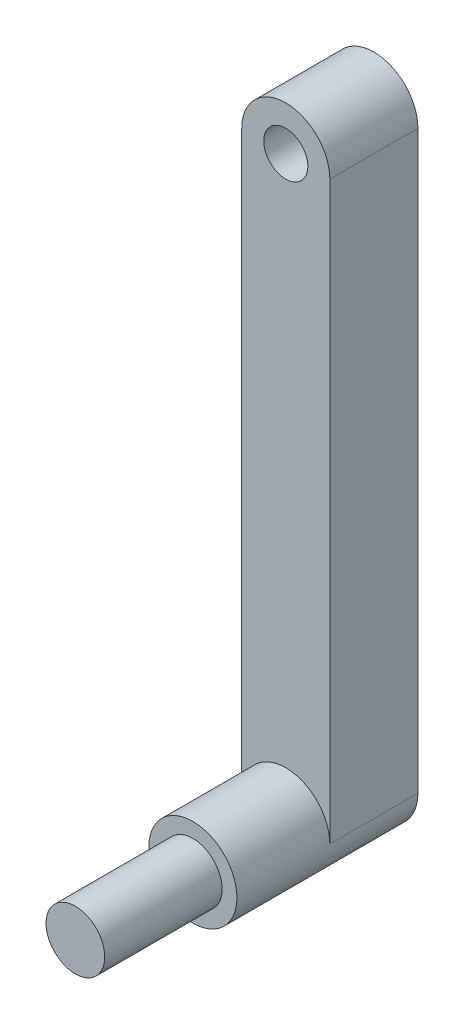
from build123d import *

# Parameters (mm, degrees)
SKETCH1_LINK3_R     = 20
BOSS_EXTRUDE1_DEPTH = 40
SKETCH2_LINK3_R     = 30
BOSS_EXTRUDE2_DEPTH = 63.3
SKETCH3_LINK3_R     = 15
BOSS_EXTRUDE3_DEPTH = 60
BOSS_EXTRUDE4_DEPTH = 0.1


with BuildPart() as part:
    # sketch1_link3 → Boss-Extrude1 (new body, symmetric)
    with BuildSketch(Plane.XY):
        Circle(SKETCH1_LINK3_R)
    extrude(amount=BOSS_EXTRUDE1_DEPTH, both=True)

    # sketch2_link3 → Boss-Extrude2 (add)
    with BuildSketch(Plane(origin=(0, 0, -40), x_dir=(-1, 0, 0), z_dir=(0, 0, -1))):
        Circle(SKETCH2_LINK3_R)
    extrude(amount=BOSS_EXTRUDE2_DEPTH)

    # sketch3_link3 → Boss-Extrude3 (add)
    with BuildSketch(Plane(origin=(0, 0, -103.3), x_dir=(-1, 0, 0), z_dir=(0, 0, -1))):
        with BuildLine():
            Line((-30, 0), (-30, 392.2))
            ThreePointArc((-30, 392.2), (0, 422.2), (30, 392.2))
            Line((30, 392.2), (30, 0))
            ThreePointArc((30, 0), (0, -30), (-30, 0))
        make_face()
        with Locations((0, 392.2)):
            Circle(SKETCH3_LINK3_R, mode=Mode.SUBTRACT)
    extrude(amount=BOSS_EXTRUDE3_DEPTH)

    # Sketch1 → Boss-Extrude4 (add)
    with BuildSketch(Plane(origin=(0, 0, -163.3), x_dir=(-1, 0, 0), z_dir=(0, 0, -1))):
        with BuildLine():
            Line((7.522174783, 134.249399585), (10, 134.249399585))
            Line((10, 134.249399585), (10, 136.696634368))
            add(Edge.make_bspline(
                [(10, 136.696634368), (9.997204903, 136.890906308), (9.991762515, 137.269176934), (9.932403331, 137.817256446), (9.84153359, 138.328261028), (9.712368999, 138.800593905), (9.551205587, 139.237248905), (9.345468962, 139.632434341), (9.106898281, 139.993681123), (8.914254013, 140.202260238), (8.818356938, 140.306089577)],
                knots=[0, 0, 0, 0, 0.000582594, 0.001134379, 0.001651743, 0.002138099, 0.002601693, 0.003045074, 0.003472233, 0.003895639, 0.003895639, 0.003895639, 0.003895639], degree=3))
            add(Edge.make_bspline(
                [(8.818356938, 140.306089577), (8.715773036, 140.401593755), (8.509158087, 140.593949383), (8.155363359, 140.838765952), (7.762731673, 141.040830434), (7.335121745, 141.211367397), (6.866877955, 141.3375283), (6.362036342, 141.428809453), (5.820670918, 141.488439288), (5.447666363, 141.493816755), (5.255725234, 141.496583898)],
                knots=[0, 0, 0, 0, 0.000420085, 0.000846097, 0.001285551, 0.001742485, 0.002224574, 0.002737584, 0.003280568, 0.003856172, 0.003856172, 0.003856172, 0.003856172], degree=3))
            Line((5.255725234, 141.496583898), (-11.1074, 141.499332628))
            Line((-11.1074, 141.499332628), (-11.1074, 138.715603063))
            Line((-11.1074, 138.715603063), (4.891397391, 138.715603063))
            add(Edge.make_bspline(
                [(4.891397391, 138.715603063), (5.113875157, 138.709389248), (5.527606615, 138.697833707), (6.094702581, 138.587548603), (6.570477779, 138.417232304), (6.811469375, 138.223649384), (6.924187535, 138.133105519)],
                knots=[0, 0, 0, 0, 0.000666363, 0.001239205, 0.001729831, 0.002160961, 0.002160961, 0.002160961, 0.002160961], degree=3))
            add(Edge.make_bspline(
                [(6.924187535, 138.133105519), (7.017801981, 138.022120901), (7.215235676, 137.788053356), (7.39227175, 137.322288951), (7.50844424, 136.768647227), (7.517031962, 136.363661229), (7.52164751, 136.145997898)],
                knots=[0, 0, 0, 0, 0.00043283, 0.000912843, 0.001473554, 0.002125085, 0.002125085, 0.002125085, 0.002125085], degree=3))
            Line((7.52164751, 136.145997898), (7.522174783, 134.249399585))
        make_face()
        with BuildLine():
            add(Edge.make_bspline(
                [(8.149278696, 148.26248533), (8.312284056, 148.450821439), (8.64098021, 148.830596403), (9.04839832, 149.474671574), (9.400009646, 150.168035775), (9.688619965, 150.915027756), (9.908283617, 151.716195033), (10.066182559, 152.570380208), (10.166025136, 153.478819295), (10.176221112, 154.103458883), (10.181450807, 154.423847509)],
                knots=[0, 0, 0, 0, 0.000746348, 0.001504992, 0.00227887, 0.003076085, 0.003902861, 0.004767389, 0.005679853, 0.006640714, 0.006640714, 0.006640714, 0.006640714], degree=3))
            add(Edge.make_bspline(
                [(10.181450807, 154.423847509), (10.176221122, 154.744236144), (10.166025165, 155.368875748), (10.066182453, 156.277314717), (9.908283984, 157.131500307), (9.688618678, 157.932666131), (9.400014212, 158.67966325), (9.04838195, 159.373009077), (8.64014015, 160.018573114), (8.309958135, 160.399301059), (8.145661262, 160.588749327)],
                knots=[0, 0, 0, 0, 0.000960861, 0.001873325, 0.002737853, 0.003564629, 0.004361844, 0.005135722, 0.005894366, 0.006645746, 0.006645746, 0.006645746, 0.006645746], degree=3))
            add(Edge.make_bspline(
                [(8.145661262, 160.588749327), (7.971032326, 160.765598355), (7.623328557, 161.11772255), (7.03352567, 161.569469278), (6.394021155, 161.954575023), (5.701623062, 162.268135578), (4.958062777, 162.5119028), (4.164694196, 162.68366789), (3.319979145, 162.785876486), (2.739307303, 162.799164055), (2.441024907, 162.805989679)],
                knots=[0, 0, 0, 0, 0.000744901, 0.001483172, 0.002221669, 0.002980209, 0.00375834, 0.004564789, 0.005411797, 0.006306475, 0.006306475, 0.006306475, 0.006306475], degree=3))
            Line((2.441024907, 162.805989679), (-11.1074, 162.808237069))
            Line((-11.1074, 162.808237069), (-11.1074, 160.024507504))
            Line((-11.1074, 160.024507504), (2.26062, 160.024507504))
            add(Edge.make_bspline(
                [(2.26062, 160.024507504), (2.481747634, 160.019728452), (2.910629485, 160.010459378), (3.531371444, 159.942085819), (4.111552413, 159.839459262), (4.648408374, 159.68466032), (5.142653648, 159.483694502), (5.597741883, 159.24618789), (6.008170627, 158.960827266), (6.374554833, 158.631131038), (6.694903235, 158.254685505), (6.975937952, 157.836858399), (7.209779798, 157.371802842), (7.404565775, 156.866534346), (7.555536313, 156.316565623), (7.659299503, 155.723850071), (7.72127444, 155.087534892), (7.729720802, 154.649698454), (7.734077724, 154.423847509)],
                knots=[0, 0, 0, 0, 0.000663246, 0.001286381, 0.001871435, 0.002428888, 0.002958967, 0.003469739, 0.003965726, 0.004454553, 0.00494418, 0.005444981, 0.005961567, 0.006502364, 0.007067131, 0.007669602, 0.008305492, 0.008982975, 0.008982975, 0.008982975, 0.008982975], degree=3))
            add(Edge.make_bspline(
                [(7.734077724, 154.423847509), (7.729720802, 154.197996564), (7.72127444, 153.760160126), (7.659299503, 153.123844947), (7.555536313, 152.531129395), (7.404565775, 151.981160672), (7.209779798, 151.475892175), (6.975937952, 151.010836621), (6.694903235, 150.593009502), (6.374554832, 150.216564018), (6.008170632, 149.886867611), (5.597741864, 149.601507669), (5.142653721, 149.363998399), (4.648408082, 149.163043105), (4.111553589, 149.008201919), (3.531366695, 148.905745891), (2.910328301, 148.836638743), (2.481058123, 148.829242426), (2.259574099, 148.82542626)],
                knots=[0, 0, 0, 0, 0.000677483, 0.001313374, 0.001915845, 0.002480611, 0.003021408, 0.003537995, 0.004038795, 0.004528423, 0.005017249, 0.005513236, 0.006024008, 0.006554087, 0.00711154, 0.007696595, 0.008319729, 0.008983942, 0.008983942, 0.008983942, 0.008983942], degree=3))
            Line((2.259574099, 148.82542626), (-11.1074, 148.828408374))
            Line((-11.1074, 148.828408374), (-11.1074, 146.044678808))
            Line((-11.1074, 146.044678808), (2.444162609, 146.044678808))
            add(Edge.make_bspline(
                [(2.444162609, 146.044678808), (2.741407481, 146.050278902), (3.321085003, 146.061200028), (4.164686986, 146.164213202), (4.958064596, 146.335745261), (5.701622595, 146.579571495), (6.394021276, 146.893116895), (7.033525638, 147.278226557), (7.623328565, 147.729972261), (7.971032328, 148.082096593), (8.145661262, 148.258945691)],
                knots=[0, 0, 0, 0, 0.00089143, 0.001738438, 0.002544887, 0.003323017, 0.004081558, 0.004820055, 0.005558326, 0.006303227, 0.006303227, 0.006303227, 0.006303227], degree=3))
            Line((8.145661262, 148.258945691), (8.149278696, 148.26248533))
        make_face()
        with BuildLine():
            add(Edge.make_bspline(
                [(8.59284, 168.327774931), (8.720690648, 168.507150573), (8.980068155, 168.871059618), (9.30145402, 169.47593218), (9.577037878, 170.131748473), (9.794642945, 170.844737361), (9.973704188, 171.606974968), (10.095436344, 172.423998107), (10.164890748, 173.293512587), (10.175827791, 173.890587982), (10.181450807, 174.197559873)],
                knots=[0, 0, 0, 0, 0.000660231, 0.001339446, 0.002049591, 0.002791461, 0.003572983, 0.004396673, 0.005266982, 0.006187896, 0.006187896, 0.006187896, 0.006187896], degree=3))
            add(Edge.make_bspline(
                [(10.181450807, 174.197559873), (10.176340347, 174.51489159), (10.166389656, 175.132775263), (10.089692931, 176.032784428), (9.968740969, 176.880630182), (9.792577856, 177.675634304), (9.562255827, 178.417062558), (9.28402116, 179.104629801), (8.957719835, 179.742021392), (8.692733943, 180.127530449), (8.56167043, 180.318205396)],
                knots=[0, 0, 0, 0, 0.000951881, 0.001853428, 0.002707758, 0.003519484, 0.004293565, 0.005034035, 0.005742689, 0.006436214, 0.006436214, 0.006436214, 0.006436214], degree=3))
            add(Edge.make_bspline(
                [(8.56167043, 180.318205396), (8.424219937, 180.493017195), (8.153115005, 180.837812909), (7.677867024, 181.286296082), (7.163329826, 181.669803902), (6.605415917, 181.98221942), (6.005452714, 182.222250284), (5.365494984, 182.394700381), (4.682241497, 182.497660943), (4.21311202, 182.510931186), (3.972292695, 182.517743231)],
                knots=[0, 0, 0, 0, 0.000666377, 0.00131435, 0.001953421, 0.002587461, 0.003226838, 0.003887088, 0.004571817, 0.005294063, 0.005294063, 0.005294063, 0.005294063], degree=3))
            add(Edge.make_bspline(
                [(3.972292695, 182.517743231), (3.77002483, 182.512003559), (3.374560915, 182.500781643), (2.795798967, 182.431807758), (2.251585712, 182.305643003), (1.736968641, 182.141175909), (1.261438918, 181.913521752), (0.809702279, 181.651629234), (0.39889761, 181.327336756), (0.012882298, 180.964284362), (-0.331664911, 180.543507554), (-0.645131399, 180.077232509), (-0.931809002, 179.56523901), (-1.176785726, 179.000317594), (-1.393494002, 178.387957053), (-1.578555436, 177.728696472), (-1.729740848, 177.020458635), (-1.801535922, 176.530344686), (-1.838558768, 176.277605712)],
                knots=[0, 0, 0, 0, 0.000606892, 0.001186565, 0.001744844, 0.002280857, 0.00280355, 0.003323463, 0.003843978, 0.004369865, 0.004910444, 0.0054714, 0.006053854, 0.006668124, 0.007316218, 0.008001334, 0.008720917, 0.009487075, 0.009487075, 0.009487075, 0.009487075], degree=3))
            Line((-1.838558768, 176.277605712), (-2.174993043, 173.3140158))
            add(Edge.make_bspline(
                [(-2.174993043, 173.3140158), (-2.199795166, 173.143544762), (-2.248011699, 172.812140764), (-2.346240966, 172.336489192), (-2.456062344, 171.894220637), (-2.583548533, 171.487408022), (-2.728446665, 171.11388167), (-2.893670555, 170.777985488), (-3.06733084, 170.471005887), (-3.208223686, 170.292592527), (-3.276888337, 170.205642113)],
                knots=[0, 0, 0, 0, 0.000516694, 0.001004477, 0.001456369, 0.001883276, 0.002282687, 0.002656777, 0.003005925, 0.003337848, 0.003337848, 0.003337848, 0.003337848], degree=3))
            add(Edge.make_bspline(
                [(-3.276888337, 170.205642113), (-3.347530094, 170.127325568), (-3.488306711, 169.971254446), (-3.72675607, 169.767624507), (-3.987754312, 169.59981453), (-4.262403523, 169.453705811), (-4.563515979, 169.350675192), (-4.881077898, 169.268483568), (-5.221589724, 169.226289788), (-5.454205799, 169.218371687), (-5.57379002, 169.214301117)],
                knots=[0, 0, 0, 0, 0.000316208, 0.000630147, 0.000937019, 0.0012458, 0.001560767, 0.001889219, 0.002228466, 0.002587379, 0.002587379, 0.002587379, 0.002587379], degree=3))
            add(Edge.make_bspline(
                [(-5.57379002, 169.214301117), (-5.709678782, 169.219198234), (-5.975306272, 169.228770837), (-6.362270717, 169.284520253), (-6.723543296, 169.386854296), (-7.057781578, 169.531289728), (-7.372225063, 169.706880695), (-7.656004706, 169.931709979), (-7.91622561, 170.195039534), (-8.064824894, 170.395459408), (-8.140655098, 170.497733656)],
                knots=[0, 0, 0, 0, 0.000407759, 0.000797063, 0.001169711, 0.001530583, 0.001887388, 0.002246819, 0.002612972, 0.002994527, 0.002994527, 0.002994527, 0.002994527], degree=3))
            add(Edge.make_bspline(
                [(-8.140655098, 170.497733656), (-8.21227436, 170.609999957), (-8.358816135, 170.83971055), (-8.540487469, 171.219471416), (-8.688110434, 171.639219428), (-8.818298974, 172.095072812), (-8.914173283, 172.591218317), (-8.976993062, 173.125351756), (-9.024779754, 173.695139303), (-9.028363381, 174.088284283), (-9.030206617, 174.290498091)],
                knots=[0, 0, 0, 0, 0.00039924, 0.000816894, 0.001259279, 0.001732843, 0.002237985, 0.002773194, 0.003345813, 0.003952269, 0.003952269, 0.003952269, 0.003952269], degree=3))
            add(Edge.make_bspline(
                [(-9.030206617, 174.290498091), (-9.028245469, 174.491220314), (-9.024447734, 174.879916109), (-8.978675009, 175.442788457), (-8.908485501, 175.967381418), (-8.813746888, 176.454879074), (-8.685319049, 176.903270827), (-8.529150969, 177.312816198), (-8.352016732, 177.688959761), (-8.201037035, 177.912328349), (-8.12737821, 178.021303714)],
                knots=[0, 0, 0, 0, 0.000602032, 0.001165827, 0.00169283, 0.00218929, 0.002654339, 0.003089966, 0.003503638, 0.003897718, 0.003897718, 0.003897718, 0.003897718], degree=3))
            add(Edge.make_bspline(
                [(-8.12737821, 178.021303714), (-8.050278011, 178.122371942), (-7.897141767, 178.323113433), (-7.62181519, 178.584800719), (-7.32107509, 178.815475721), (-6.99220558, 179.012127902), (-6.631310042, 179.167875726), (-6.242262606, 179.289037333), (-5.825539193, 179.386078264), (-5.535944561, 179.414252276), (-5.387913583, 179.428653878)],
                knots=[0, 0, 0, 0, 0.000380836, 0.000756415, 0.001135265, 0.001516281, 0.001902732, 0.002311427, 0.002737691, 0.003183429, 0.003183429, 0.003183429, 0.003183429], degree=3))
            Line((-5.387913583, 179.428653878), (-5.386988696, 182.124061018))
            add(Edge.make_bspline(
                [(-5.386988696, 182.124061018), (-5.628590508, 182.094948059), (-6.099154812, 182.038245176), (-6.775046283, 181.873658729), (-7.407304526, 181.667667891), (-7.995724135, 181.407874037), (-8.533210838, 181.085292136), (-9.028475589, 180.716376837), (-9.480824673, 180.294903719), (-9.740432555, 179.974780636), (-9.871076212, 179.813683639)],
                knots=[0, 0, 0, 0, 0.000729467, 0.001420773, 0.002082741, 0.002722623, 0.003345758, 0.00395915, 0.004572799, 0.005194438, 0.005194438, 0.005194438, 0.005194438], degree=3))
            add(Edge.make_bspline(
                [(-9.871076212, 179.813683639), (-9.992477828, 179.640309342), (-10.23814057, 179.289477065), (-10.548807081, 178.71473424), (-10.802917482, 178.091256904), (-11.016845391, 177.422619659), (-11.183693991, 176.706328058), (-11.301949018, 175.941555857), (-11.373669129, 175.131278428), (-11.380923911, 174.575365024), (-11.384641482, 174.290498091)],
                knots=[0, 0, 0, 0, 0.000634596, 0.001284139, 0.001954793, 0.002651798, 0.00338821, 0.00415874, 0.00497172, 0.005826153, 0.005826153, 0.005826153, 0.005826153], degree=3))
            add(Edge.make_bspline(
                [(-11.384641482, 174.290498091), (-11.379021386, 173.99680319), (-11.368103204, 173.426241082), (-11.298591955, 172.5934478), (-11.175091017, 171.809625772), (-11.002625469, 171.071266177), (-10.783574893, 170.38029542), (-10.511714988, 169.737029006), (-10.190840534, 169.141668773), (-9.935166461, 168.778287882), (-9.809117399, 168.599138624)],
                knots=[0, 0, 0, 0, 0.0008811, 0.001711717, 0.002504794, 0.003259452, 0.003984445, 0.004676557, 0.005351883, 0.006008578, 0.006008578, 0.006008578, 0.006008578], degree=3))
            add(Edge.make_bspline(
                [(-9.809117399, 168.599138624), (-9.675856131, 168.43331859), (-9.412334599, 168.105412739), (-8.953925545, 167.681596445), (-8.4562622, 167.32138851), (-7.918061611, 167.030340369), (-7.342935788, 166.796795805), (-6.725961797, 166.633943934), (-6.069737891, 166.535010147), (-5.618401495, 166.524473583), (-5.387913583, 166.519092784)],
                knots=[0, 0, 0, 0, 0.00063749, 0.001260625, 0.00186616, 0.002476143, 0.003091687, 0.003723995, 0.004386185, 0.005077278, 0.005077278, 0.005077278, 0.005077278], degree=3))
            add(Edge.make_bspline(
                [(-5.387913583, 166.519092784), (-5.188468775, 166.522217998), (-4.799854332, 166.528307418), (-4.234519257, 166.608281989), (-3.700308146, 166.72525768), (-3.197944619, 166.892804451), (-2.730660285, 167.112692714), (-2.291312429, 167.373789613), (-1.887848799, 167.691400124), (-1.515301478, 168.054821875), (-1.176964013, 168.466699967), (-0.869926978, 168.923834174), (-0.602091393, 169.433591041), (-0.356886336, 169.98664491), (-0.150402058, 170.58979477), (0.019939037, 171.241489962), (0.168648826, 171.937941594), (0.234352132, 172.422344796), (0.268040849, 172.670717714)],
                knots=[0, 0, 0, 0, 0.00059787, 0.001164938, 0.00170929, 0.002236906, 0.002749706, 0.003255953, 0.003766763, 0.00428628, 0.004814397, 0.005363068, 0.005935276, 0.006539662, 0.007176477, 0.007845274, 0.008559612, 0.009311305, 0.009311305, 0.009311305, 0.009311305], degree=3))
            Line((0.268040849, 172.670717714), (0.608736522, 175.516527105))
            add(Edge.make_bspline(
                [(0.608736522, 175.516527105), (0.628176383, 175.692452981), (0.665770838, 176.032673376), (0.764851183, 176.521204972), (0.865615116, 176.976655959), (0.995113548, 177.396688457), (1.146526954, 177.779619503), (1.306723301, 178.132272345), (1.494600798, 178.445401172), (1.636857876, 178.633208544), (1.706370419, 178.724978796)],
                knots=[0, 0, 0, 0, 0.000530698, 0.00102631, 0.00149436, 0.001929717, 0.002343105, 0.002729176, 0.003090455, 0.003435683, 0.003435683, 0.003435683, 0.003435683], degree=3))
            add(Edge.make_bspline(
                [(1.706370419, 178.724978796), (1.779790549, 178.807866394), (1.925406946, 178.972259911), (2.175297786, 179.18727653), (2.451708102, 179.362509906), (2.747417405, 179.511639439), (3.066692921, 179.626834464), (3.410191083, 179.704674265), (3.774634358, 179.754639286), (4.02523053, 179.761488989), (4.153743502, 179.765001716)],
                knots=[0, 0, 0, 0, 0.000331952, 0.00065837, 0.000984908, 0.001311477, 0.001650261, 0.002000222, 0.002366374, 0.002751811, 0.002751811, 0.002751811, 0.002751811], degree=3))
            add(Edge.make_bspline(
                [(4.153743502, 179.765001716), (4.301490575, 179.760664102), (4.588017243, 179.752252145), (5.003982194, 179.689714741), (5.391334817, 179.585067896), (5.748524562, 179.431755039), (6.080295098, 179.240950713), (6.381649625, 179.004659752), (6.655319551, 178.727618142), (6.894850873, 178.404270517), (7.106456416, 178.039765073), (7.292867895, 177.633693322), (7.452233253, 177.185253984), (7.578968966, 176.693327089), (7.675047919, 176.159057988), (7.744167408, 175.58421941), (7.790372991, 174.966895036), (7.794106949, 174.541373208), (7.796036536, 174.321477497)],
                knots=[0, 0, 0, 0, 0.000443116, 0.000859337, 0.001258748, 0.001643447, 0.00202222, 0.002403775, 0.002788703, 0.00318701, 0.003607514, 0.004051072, 0.004525606, 0.00503334, 0.005573267, 0.00615294, 0.006769692, 0.007429244, 0.007429244, 0.007429244, 0.007429244], degree=3))
            add(Edge.make_bspline(
                [(7.796036536, 174.321477497), (7.794066279, 174.10895187), (7.790230606, 173.695209387), (7.744094245, 173.095630605), (7.676034822, 172.533477216), (7.572504012, 172.010801701), (7.448770021, 171.523661483), (7.285607451, 171.078427877), (7.104753012, 170.667183929), (6.950686673, 170.419462879), (6.875505611, 170.298580331)],
                knots=[0, 0, 0, 0, 0.000637429, 0.001240939, 0.001803047, 0.002335099, 0.002838552, 0.003308919, 0.003756499, 0.004183062, 0.004183062, 0.004183062, 0.004183062], degree=3))
            add(Edge.make_bspline(
                [(6.875505611, 170.298580331), (6.795332979, 170.187494973), (6.636334934, 169.967190934), (6.354862055, 169.670917405), (6.032118636, 169.418865492), (5.676835049, 169.199547095), (5.284142743, 169.024744653), (4.859755358, 168.880370119), (4.397699468, 168.780048799), (4.075958463, 168.742424393), (3.910333883, 168.723056248)],
                knots=[0, 0, 0, 0, 0.000410702, 0.000814503, 0.001220915, 0.001636099, 0.0020639, 0.002507546, 0.002978932, 0.003479028, 0.003479028, 0.003479028, 0.003479028], degree=3))
            Line((3.910333883, 168.723056248), (3.912503478, 166.033492322))
            add(Edge.make_bspline(
                [(3.912503478, 166.033492322), (4.161612545, 166.057024502), (4.648733222, 166.103040536), (5.354355573, 166.239344735), (6.0147514, 166.438704234), (6.625760102, 166.699541339), (7.190658885, 167.017980632), (7.711579685, 167.389795241), (8.185439792, 167.824974483), (8.45637152, 168.157493137), (8.592649836, 168.324749598)],
                knots=[0, 0, 0, 0, 0.000750352, 0.001467276, 0.002151877, 0.00281609, 0.003456156, 0.004093585, 0.004732472, 0.005379068, 0.005379068, 0.005379068, 0.005379068], degree=3))
            Line((8.592649836, 168.324749598), (8.59284, 168.327774931))
        make_face()
        Polygon((-8.629574783, 200.38965371), (-11.1074, 200.38965371), (-11.1074, 183.993180666), (-8.629574783, 183.993180666), (-8.629574783, 190.814847623), (10, 190.814847623), (10, 193.567986753), (-8.629574783, 193.567986753), align=None)
        with BuildLine():
            add(Edge.make_bspline(
                [(0.929936087, 218.309152671), (0.825743682, 218.230964221), (0.617972304, 218.075047654), (0.333962249, 217.806250579), (0.073424371, 217.513521711), (-0.169072491, 217.19716172), (-0.384444433, 216.850762486), (-0.579292266, 216.47993857), (-0.748767731, 216.081020435), (-0.84310259, 215.803555866), (-0.891474066, 215.66128215)],
                knots=[0, 0, 0, 0, 0.000390546, 0.000778792, 0.001170579, 0.001565354, 0.001973017, 0.002392683, 0.002820964, 0.003271683, 0.003271683, 0.003271683, 0.003271683], degree=3))
            add(Edge.make_bspline(
                [(-0.891474066, 215.66128215), (-0.988454311, 215.90561556), (-1.177599651, 216.382151023), (-1.585853391, 217.017733063), (-2.05910447, 217.579261976), (-2.44326175, 217.870317021), (-2.635172068, 218.015717016)],
                knots=[0, 0, 0, 0, 0.000786842, 0.001534616, 0.002256116, 0.002976352, 0.002976352, 0.002976352, 0.002976352], degree=3))
            add(Edge.make_bspline(
                [(-2.635172068, 218.015717016), (-2.839284878, 218.144310545), (-3.248153929, 218.401902972), (-3.939127978, 218.653275891), (-4.676726108, 218.814415511), (-5.187856637, 218.833517605), (-5.449872395, 218.843309722)],
                knots=[0, 0, 0, 0, 0.000721866, 0.001446008, 0.002192484, 0.002977619, 0.002977619, 0.002977619, 0.002977619], degree=3))
            add(Edge.make_bspline(
                [(-5.449872395, 218.843309722), (-5.674399271, 218.838927893), (-6.111849204, 218.830390693), (-6.747388826, 218.743374593), (-7.342315794, 218.608201505), (-7.896008034, 218.41868495), (-8.406101908, 218.168753288), (-8.872245777, 217.860142288), (-9.302890494, 217.502823618), (-9.548567241, 217.222607338), (-9.671922887, 217.081909203)],
                knots=[0, 0, 0, 0, 0.00067322, 0.001311646, 0.001920343, 0.002501181, 0.003063288, 0.003619335, 0.004175223, 0.004735812, 0.004735812, 0.004735812, 0.004735812], degree=3))
            add(Edge.make_bspline(
                [(-9.671922887, 217.081909203), (-9.787667056, 216.929468493), (-10.022586977, 216.620067512), (-10.313614011, 216.099875506), (-10.560570196, 215.531576595), (-10.76524611, 214.914217057), (-10.916612525, 214.245137768), (-11.032901671, 213.528605963), (-11.098052062, 212.760754475), (-11.106107451, 212.233012445), (-11.110252456, 211.961455934)],
                knots=[0, 0, 0, 0, 0.000573644, 0.001164296, 0.001782618, 0.002430591, 0.003112268, 0.003838395, 0.004606901, 0.005421517, 0.005421517, 0.005421517, 0.005421517], degree=3))
            Line((-11.110252456, 211.961455934), (-11.1074, 202.692735715))
            Line((-11.1074, 202.692735715), (10, 202.692735715))
            Line((10, 202.692735715), (10, 212.145180062))
            add(Edge.make_bspline(
                [(10, 212.145180062), (9.996269797, 212.423388311), (9.989003958, 212.965293355), (9.917910221, 213.752837245), (9.798735911, 214.490722578), (9.635886068, 215.177440012), (9.431257599, 215.81576314), (9.167233856, 216.396485968), (8.86373359, 216.930128564), (8.61992993, 217.248160342), (8.499711618, 217.404980152)],
                knots=[0, 0, 0, 0, 0.000834464, 0.001625402, 0.002369711, 0.003074957, 0.003741128, 0.004376973, 0.00498575, 0.005577942, 0.005577942, 0.005577942, 0.005577942], degree=3))
            add(Edge.make_bspline(
                [(8.499711618, 217.404980152), (8.370400808, 217.550062145), (8.114138095, 217.837579521), (7.669595421, 218.206871016), (7.183897232, 218.519749281), (6.652912755, 218.770608367), (6.082577226, 218.972322993), (5.467813478, 219.111866219), (4.809703018, 219.197580184), (4.356121834, 219.20620149), (4.122764096, 219.210636966)],
                knots=[0, 0, 0, 0, 0.00058237, 0.001154116, 0.001727419, 0.002311367, 0.002911835, 0.003538777, 0.004199145, 0.004898899, 0.004898899, 0.004898899, 0.004898899], degree=3))
            add(Edge.make_bspline(
                [(4.122764096, 219.210636966), (3.966277301, 219.20856249), (3.658547493, 219.204483051), (3.207696085, 219.158344824), (2.776068842, 219.087648148), (2.363790605, 218.992283476), (1.973465055, 218.863040114), (1.604246396, 218.70644023), (1.251642608, 218.528024857), (1.035194381, 218.380992374), (0.927459636, 218.307808559)],
                knots=[0, 0, 0, 0, 0.000469305, 0.000922883, 0.00135797, 0.001780913, 0.002190971, 0.002589621, 0.002983527, 0.003373887, 0.003373887, 0.003373887, 0.003373887], degree=3))
            Line((0.927459636, 218.307808559), (0.929936087, 218.309152671))
        make_face()
        with BuildLine():
            Line((-8.660165217, 205.47646528), (-8.660165217, 212.022818323))
            add(Edge.make_bspline(
                [(-8.660165217, 212.022818323), (-8.659035574, 212.186875694), (-8.656834979, 212.506466768), (-8.614093694, 212.968876217), (-8.55572718, 213.403129303), (-8.462433851, 213.802180851), (-8.346995754, 214.171274962), (-8.206874886, 214.507180243), (-8.039066709, 214.812875374), (-7.902414752, 214.993027733), (-7.835286667, 215.081524693)],
                knots=[0, 0, 0, 0, 0.000491955, 0.00095835, 0.001392084, 0.001805401, 0.002186108, 0.002551055, 0.002895799, 0.003228664, 0.003228664, 0.003228664, 0.003228664], degree=3))
            add(Edge.make_bspline(
                [(-7.835286667, 215.081524693), (-7.763100157, 215.161226434), (-7.619238838, 215.320064942), (-7.374597259, 215.531856529), (-7.096631606, 215.703520758), (-6.793701343, 215.846142979), (-6.463802505, 215.956135576), (-6.108224154, 216.036716742), (-5.725255531, 216.078656307), (-5.461762456, 216.086516806), (-5.325954771, 216.090568207)],
                knots=[0, 0, 0, 0, 0.000322464, 0.000642642, 0.000966803, 0.001299403, 0.001645084, 0.002007986, 0.002391154, 0.002798697, 0.002798697, 0.002798697, 0.002798697], degree=3))
            add(Edge.make_bspline(
                [(-5.325954771, 216.090568207), (-5.190198629, 216.086309493), (-4.926805558, 216.078046769), (-4.544233559, 216.039048192), (-4.192144931, 215.94906652), (-3.862301504, 215.844262462), (-3.565200433, 215.693520007), (-3.288579737, 215.522083756), (-3.046028939, 215.307736758), (-2.904866722, 215.145096482), (-2.834325393, 215.063822175)],
                knots=[0, 0, 0, 0, 0.000407543, 0.000790711, 0.001150305, 0.001495986, 0.001826519, 0.002146942, 0.002470013, 0.00279272, 0.00279272, 0.00279272, 0.00279272], degree=3))
            add(Edge.make_bspline(
                [(-2.834325393, 215.063822175), (-2.76841123, 214.975420316), (-2.633348787, 214.794279109), (-2.472916057, 214.483500194), (-2.329317886, 214.144405985), (-2.221895891, 213.768970513), (-2.133256597, 213.364014317), (-2.065746618, 212.926743847), (-2.032991892, 212.454683423), (-2.027353438, 212.129669744), (-2.024435204, 211.961455934)],
                knots=[0, 0, 0, 0, 0.000330295, 0.000676797, 0.001045827, 0.001433695, 0.001846039, 0.002289177, 0.002759628, 0.003264324, 0.003264324, 0.003264324, 0.003264324], degree=3))
            Line((-2.024435204, 211.961455934), (-2.02204087, 205.47646528))
            Line((-2.02204087, 205.47646528), (-8.660165217, 205.47646528))
        make_face(mode=Mode.SUBTRACT)
        with BuildLine():
            add(Edge.make_bspline(
                [(6.665642609, 215.387766149), (6.736042296, 215.295894122), (6.87927443, 215.1089753), (7.062328286, 214.796521307), (7.210288136, 214.446876), (7.340520283, 214.06629581), (7.437034573, 213.648049698), (7.499071338, 213.196108549), (7.54741982, 212.711882361), (7.550852916, 212.377600564), (7.552626916, 212.204865553)],
                knots=[0, 0, 0, 0, 0.00034703, 0.000706052, 0.001082621, 0.001484282, 0.001911532, 0.002367802, 0.002852221, 0.00337019, 0.00337019, 0.00337019, 0.00337019], degree=3))
            Line((7.552626916, 212.204865553), (7.552765217, 205.47646528))
            Line((7.552765217, 205.47646528), (0.425193913, 205.47646528))
            Line((0.425193913, 205.47646528), (0.425193913, 212.022818323))
            add(Edge.make_bspline(
                [(0.425193913, 212.022818323), (0.426718619, 212.200110177), (0.429669063, 212.543185983), (0.469134405, 213.04186251), (0.540514703, 213.507340421), (0.635373077, 213.939995171), (0.76046315, 214.338113758), (0.909880609, 214.701794198), (1.086486695, 215.033095212), (1.295782587, 215.326686361), (1.532999625, 215.585682373), (1.794586995, 215.813388619), (2.084943238, 216.004840988), (2.402869507, 216.161478987), (2.749644692, 216.280359215), (3.124008218, 216.362285907), (3.523658949, 216.417857045), (3.799494054, 216.423839959), (3.941313289, 216.426916045)],
                knots=[0, 0, 0, 0, 0.000531786, 0.001029054, 0.00149911, 0.001943616, 0.002356529, 0.00274939, 0.003121669, 0.003480254, 0.003827969, 0.004173111, 0.004518027, 0.004868351, 0.005233646, 0.005614791, 0.006016622, 0.006441851, 0.006441851, 0.006441851, 0.006441851], degree=3))
            add(Edge.make_bspline(
                [(3.941313289, 216.426916045), (4.088985063, 216.423411239), (4.376303841, 216.416592086), (4.792219308, 216.367035266), (5.180122838, 216.290171294), (5.536852149, 216.173003358), (5.865726963, 216.028064183), (6.165824369, 215.850188134), (6.434341502, 215.637262863), (6.586982481, 215.470183639), (6.663075398, 215.386893125)],
                knots=[0, 0, 0, 0, 0.000442917, 0.000861765, 0.001254949, 0.001627228, 0.001985814, 0.002331155, 0.002671209, 0.003009241, 0.003009241, 0.003009241, 0.003009241], degree=3))
            Line((6.663075398, 215.386893125), (6.665642609, 215.387766149))
        make_face(mode=Mode.SUBTRACT)
        with BuildLine():
            add(Edge.make_bspline(
                [(7.935145652, 225.02852881), (8.122593653, 225.223902892), (8.497616391, 225.614783151), (8.969279986, 226.28298907), (9.375766682, 227.00450985), (9.708436748, 227.788044034), (9.964416047, 228.632534733), (10.142509922, 229.535500705), (10.256951328, 230.496001494), (10.268467561, 231.156543867), (10.274389026, 231.496184308)],
                knots=[0, 0, 0, 0, 0.000811286, 0.001623121, 0.002445443, 0.003292127, 0.004171303, 0.005087846, 0.006050164, 0.007068674, 0.007068674, 0.007068674, 0.007068674], degree=3))
            add(Edge.make_bspline(
                [(10.274389026, 231.496184308), (10.268477416, 231.838776176), (10.256977845, 232.505203693), (10.14233442, 233.474464564), (9.965188306, 234.385047133), (9.707489134, 235.236312446), (9.375945759, 236.027537021), (8.969213787, 236.757689927), (8.498390739, 237.435303699), (8.121521184, 237.830811343), (7.933231049, 238.02841337)],
                knots=[0, 0, 0, 0, 0.001027356, 0.001998467, 0.002923688, 0.003807097, 0.004661931, 0.005491982, 0.006311022, 0.007128806, 0.007128806, 0.007128806, 0.007128806], degree=3))
            add(Edge.make_bspline(
                [(7.933231049, 238.02841337), (7.731233426, 238.214022039), (7.323175699, 238.588972251), (6.619765744, 239.053301746), (5.852745536, 239.456370582), (5.013443494, 239.781606267), (4.103398293, 240.035419852), (3.121742465, 240.205956088), (2.070546928, 240.321609665), (1.345279202, 240.332818574), (0.971715931, 240.33859194)],
                knots=[0, 0, 0, 0, 0.000821834, 0.001660195, 0.002519315, 0.003417587, 0.004354995, 0.005348951, 0.006403644, 0.007523888, 0.007523888, 0.007523888, 0.007523888], degree=3))
            Line((0.971715931, 240.33859194), (-2.113812174, 240.339041418))
            add(Edge.make_bspline(
                [(-2.113812174, 240.339041418), (-2.488521313, 240.332657999), (-3.213272069, 240.320311387), (-4.264624686, 240.211252802), (-5.244899712, 240.040299476), (-6.152612217, 239.783677711), (-6.995017294, 239.471342254), (-7.759176544, 239.069928054), (-8.465539383, 238.616236735), (-8.872680022, 238.243917724), (-9.074462911, 238.059392776)],
                knots=[0, 0, 0, 0, 0.001123818, 0.002173653, 0.003167608, 0.004105017, 0.0050001, 0.005857176, 0.006690618, 0.00750955, 0.00750955, 0.00750955, 0.00750955], degree=3))
            add(Edge.make_bspline(
                [(-9.074462911, 238.059392776), (-9.262671574, 237.864751966), (-9.639226081, 237.475328477), (-10.111726019, 236.805906216), (-10.515881158, 236.081631658), (-10.848933874, 235.298554164), (-11.10635243, 234.455935828), (-11.284025228, 233.55277041), (-11.397967671, 232.590756904), (-11.409635012, 231.92875805), (-11.415620888, 231.589122526)],
                knots=[0, 0, 0, 0, 0.000811243, 0.001623078, 0.002449261, 0.003295946, 0.004170889, 0.005087433, 0.006054147, 0.007072657, 0.007072657, 0.007072657, 0.007072657], degree=3))
            add(Edge.make_bspline(
                [(-11.415620888, 231.589122526), (-11.409709278, 231.246530657), (-11.398209707, 230.58010314), (-11.283566283, 229.61084227), (-11.106420168, 228.700259701), (-10.848720997, 227.848994388), (-10.517177622, 227.057769812), (-10.11044565, 226.327616906), (-9.639622601, 225.650003134), (-9.262753046, 225.25449549), (-9.074462911, 225.056893464)],
                knots=[0, 0, 0, 0, 0.001027356, 0.001998467, 0.002923688, 0.003807097, 0.004661931, 0.005491982, 0.006311022, 0.007128806, 0.007128806, 0.007128806, 0.007128806], degree=3))
            add(Edge.make_bspline(
                [(-9.074462911, 225.056893464), (-8.872478095, 224.871249865), (-8.464446238, 224.49622909), (-7.760837624, 224.032441442), (-6.99507891, 223.627473734), (-6.152810599, 223.310741962), (-5.245642592, 223.047908522), (-4.264230384, 222.880310186), (-3.21480658, 222.763304183), (-2.490960449, 222.752362201), (-2.117373423, 222.746714893)],
                knots=[0, 0, 0, 0, 0.000821834, 0.001660195, 0.002519315, 0.003415983, 0.004354592, 0.005348547, 0.00639884, 0.007519084, 0.007519084, 0.007519084, 0.007519084], degree=3))
            Line((-2.117373423, 222.746714893), (0.975821739, 222.749541418))
            add(Edge.make_bspline(
                [(0.975821739, 222.749541418), (1.3479743, 222.754678097), (2.071666772, 222.764666947), (3.12194993, 222.873886914), (4.103666648, 223.04498643), (5.011380653, 223.301634324), (5.853785356, 223.613963277), (6.6179447, 224.015379111), (7.324307516, 224.469070018), (7.731448158, 224.841389082), (7.933231049, 225.025914058)],
                knots=[0, 0, 0, 0, 0.001116054, 0.002170292, 0.003164248, 0.004101656, 0.004996739, 0.005853816, 0.006687257, 0.00750619, 0.00750619, 0.00750619, 0.00750619], degree=3))
            Line((7.933231049, 225.025914058), (7.935145652, 225.02852881))
        make_face()
        with BuildLine():
            add(Edge.make_bspline(
                [(6.115014783, 236.086970983), (6.246529941, 235.956820414), (6.510722865, 235.69536873), (6.8478588, 235.24337574), (7.13045997, 234.743774096), (7.36846549, 234.19898275), (7.547159676, 233.604303231), (7.674716124, 232.964136529), (7.750029428, 232.276891556), (7.759933008, 231.803220808), (7.76505713, 231.55814312)],
                knots=[0, 0, 0, 0, 0.000554498, 0.001113899, 0.001684788, 0.002273463, 0.002893636, 0.003543721, 0.004229408, 0.004964543, 0.004964543, 0.004964543, 0.004964543], degree=3))
            add(Edge.make_bspline(
                [(7.76505713, 231.55814312), (7.759872363, 231.311594364), (7.749818808, 230.833522502), (7.674946558, 230.140382824), (7.547946911, 229.495554041), (7.367414993, 228.898557464), (7.131454975, 228.351489365), (6.84904617, 227.851323441), (6.509639286, 227.402736278), (6.245928435, 227.142779116), (6.114297347, 227.013021679)],
                knots=[0, 0, 0, 0, 0.000739557, 0.001434042, 0.002088467, 0.00270864, 0.003301377, 0.003872266, 0.004428136, 0.004982118, 0.004982118, 0.004982118, 0.004982118], degree=3))
            add(Edge.make_bspline(
                [(6.114297347, 227.013021679), (5.969628676, 226.892607607), (5.676219942, 226.648390666), (5.171791949, 226.346860471), (4.611701704, 226.096972313), (3.99796239, 225.889706506), (3.329200619, 225.724438374), (2.603281185, 225.614369137), (1.8214851, 225.540559877), (1.28169537, 225.533885557), (1.002695337, 225.530435815)],
                knots=[0, 0, 0, 0, 0.000564003, 0.001143879, 0.001755913, 0.002401099, 0.003084841, 0.003819709, 0.004601832, 0.005438568, 0.005438568, 0.005438568, 0.005438568], degree=3))
            Line((1.002695337, 225.530435815), (-1.96086, 225.533270983))
            add(Edge.make_bspline(
                [(-1.96086, 225.533270983), (-2.250718131, 225.535531227), (-2.810199337, 225.539893925), (-3.617673682, 225.613732151), (-4.366730421, 225.725726063), (-5.056547099, 225.88864887), (-5.688580633, 226.095083954), (-6.260294008, 226.34829178), (-6.776676108, 226.646828724), (-7.077006256, 226.892386312), (-7.224549803, 227.013021679)],
                knots=[0, 0, 0, 0, 0.000869254, 0.001677825, 0.002430182, 0.003139733, 0.003801702, 0.004421811, 0.005013076, 0.005584051, 0.005584051, 0.005584051, 0.005584051], degree=3))
            add(Edge.make_bspline(
                [(-7.224549803, 227.013021679), (-7.359470326, 227.14246602), (-7.628923425, 227.400982501), (-7.971233772, 227.852684509), (-8.265904373, 228.348707086), (-8.497818352, 228.899779336), (-8.686774575, 229.49449444), (-8.809811792, 230.140880515), (-8.892789347, 230.833130825), (-8.901696844, 231.311517078), (-8.906288992, 231.55814312)],
                knots=[0, 0, 0, 0, 0.00056017, 0.001118729, 0.001694061, 0.002286798, 0.00290828, 0.003562705, 0.004257684, 0.004997241, 0.004997241, 0.004997241, 0.004997241], degree=3))
            add(Edge.make_bspline(
                [(-8.906288992, 231.55814312), (-8.901761805, 231.80329934), (-8.893008865, 232.277288508), (-8.809581963, 232.963636002), (-8.685983278, 233.605362051), (-8.498873948, 234.197758315), (-8.264907755, 234.746567302), (-7.969944405, 235.241908907), (-7.630420207, 235.697295486), (-7.359686962, 235.956286198), (-7.224549803, 236.085562043)],
                knots=[0, 0, 0, 0, 0.000735134, 0.001421321, 0.002071407, 0.002692888, 0.003281564, 0.003856896, 0.004418968, 0.004979138, 0.004979138, 0.004979138, 0.004979138], degree=3))
            add(Edge.make_bspline(
                [(-7.224549803, 236.085562043), (-7.076882211, 236.206036217), (-6.77571384, 236.451743554), (-6.259496633, 236.753703232), (-5.690805099, 237.018798309), (-5.056284312, 237.222841989), (-4.36636652, 237.38488759), (-3.618148021, 237.504342585), (-2.810629871, 237.575185306), (-2.25176595, 237.582212749), (-1.962476392, 237.585850425)],
                knots=[0, 0, 0, 0, 0.000570975, 0.001164504, 0.001788267, 0.002450235, 0.003159787, 0.003912833, 0.004721404, 0.00558911, 0.00558911, 0.00558911, 0.00558911], degree=3))
            Line((-1.962476392, 237.585850425), (1.006412174, 237.585902288))
            add(Edge.make_bspline(
                [(1.006412174, 237.585902288), (1.284148658, 237.582243648), (1.822651265, 237.575149921), (2.603761143, 237.503523426), (3.32882959, 237.38623525), (3.99770719, 237.221797398), (4.613932783, 237.016852006), (5.171007458, 236.75516201), (5.675240957, 236.450200903), (5.969501148, 236.20581612), (6.114297347, 236.085562043)],
                knots=[0, 0, 0, 0, 0.000833022, 0.001615145, 0.002350719, 0.003034461, 0.003679647, 0.004295382, 0.004877567, 0.00544157, 0.00544157, 0.00544157, 0.00544157], degree=3))
            Line((6.114297347, 236.085562043), (6.115014783, 236.086970983))
        make_face(mode=Mode.SUBTRACT)
        Polygon((-8.629574783, 258.737152323), (-11.1074, 258.737152323), (-11.1074, 242.34067928), (-8.629574783, 242.34067928), (-8.629574783, 249.162346236), (10, 249.162346236), (10, 251.915485367), (-8.629574783, 251.915485367), align=None)
    extrude(amount=BOSS_EXTRUDE4_DEPTH)


solid = part.part
